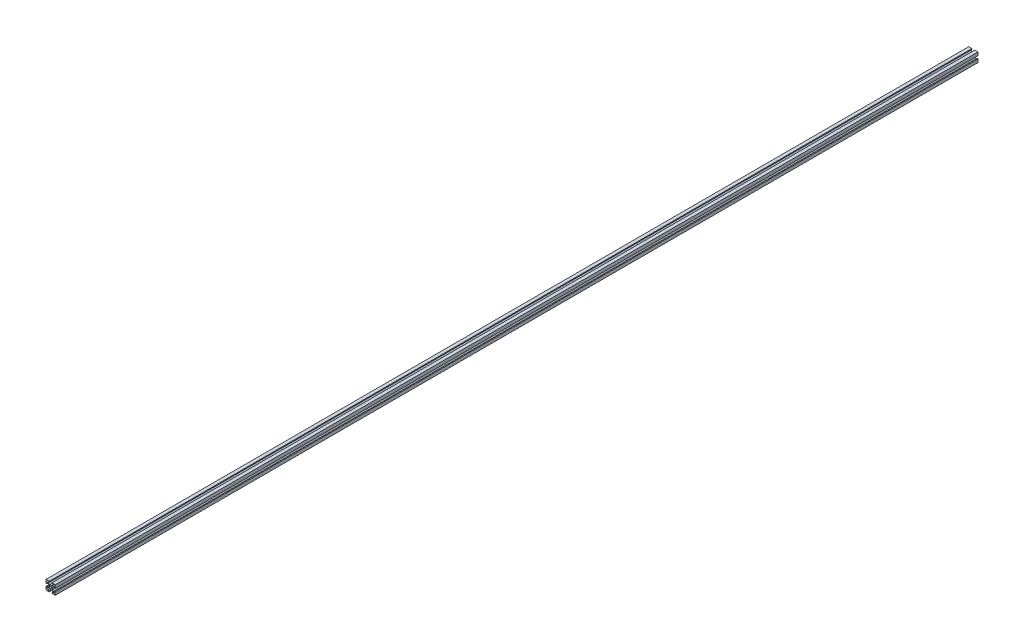
from build123d import *

# Parameters (mm, degrees)
BOSS_EXTRU_1_DEPTH           = 1000
R_P_TITION_CIRCULAIRE1_COUNT = 4


with BuildPart() as part:
    # Esquisse1 → Boss.-Extru.1 (new body)
    with BuildSketch(Plane.XY):
        with BuildLine():
            Line((0, 2), (0, 1.25))
            ThreePointArc((0, 1.25), (-0.883883476, 0.883883476), (-1.25, 0))
            Line((-1.25, 0), (-2, 0))
            Line((-2, 0), (-2, 1))
            Line((-2, 1), (-3.735093334, 3.067803714))
            ThreePointArc((-3.735093334, 3.067803714), (-3.901303021, 3.112339465), (-4, 2.971385572))
            Line((-4, 2.971385572), (-4, 1.5))
            Line((-4, 1.5), (-5, 1.5))
            Line((-5, 1.5), (-5, 5))
            Line((-5, 5), (-1.5, 5))
            Line((-1.5, 5), (-1.5, 4))
            Line((-1.5, 4), (-2.971385572, 4))
            ThreePointArc((-2.971385572, 4), (-3.112339465, 3.901303021), (-3.067803714, 3.735093334))
            Line((-3.067803714, 3.735093334), (-1, 2))
            Line((-1, 2), (0, 2))
        make_face()
    boss_extru_1 = extrude(amount=BOSS_EXTRU_1_DEPTH)

    # Répétition circulaire1: Boss.-Extru.1 ×4 about axis
    r_p_tition_circulaire1_axis = Axis((0, 0, 105), (0, 0, -1))
    for i in range(1, R_P_TITION_CIRCULAIRE1_COUNT):
        add(boss_extru_1.rotate(r_p_tition_circulaire1_axis, i * 360 / R_P_TITION_CIRCULAIRE1_COUNT))


solid = part.part
